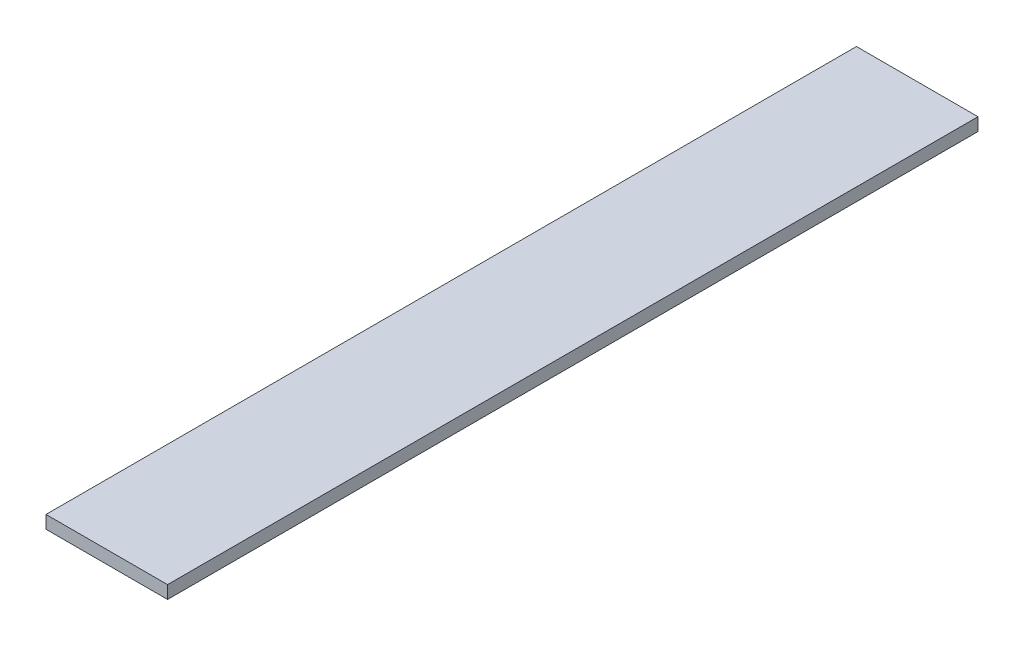
from build123d import *

# Parameters (mm, degrees)
SKETCH1_W           = 30
SKETCH1_H           = 200
BOSS_EXTRUDE1_DEPTH = 3.175


with BuildPart() as part:
    # Sketch1 → Boss-Extrude1 (new body)
    with BuildSketch(Plane(origin=(0, 0, 0), x_dir=(1, 0, 0), z_dir=(0, 1, 0))):
        with Locations((15, 100)):
            Rectangle(SKETCH1_W, SKETCH1_H)
    extrude(amount=BOSS_EXTRUDE1_DEPTH)


solid = part.part
